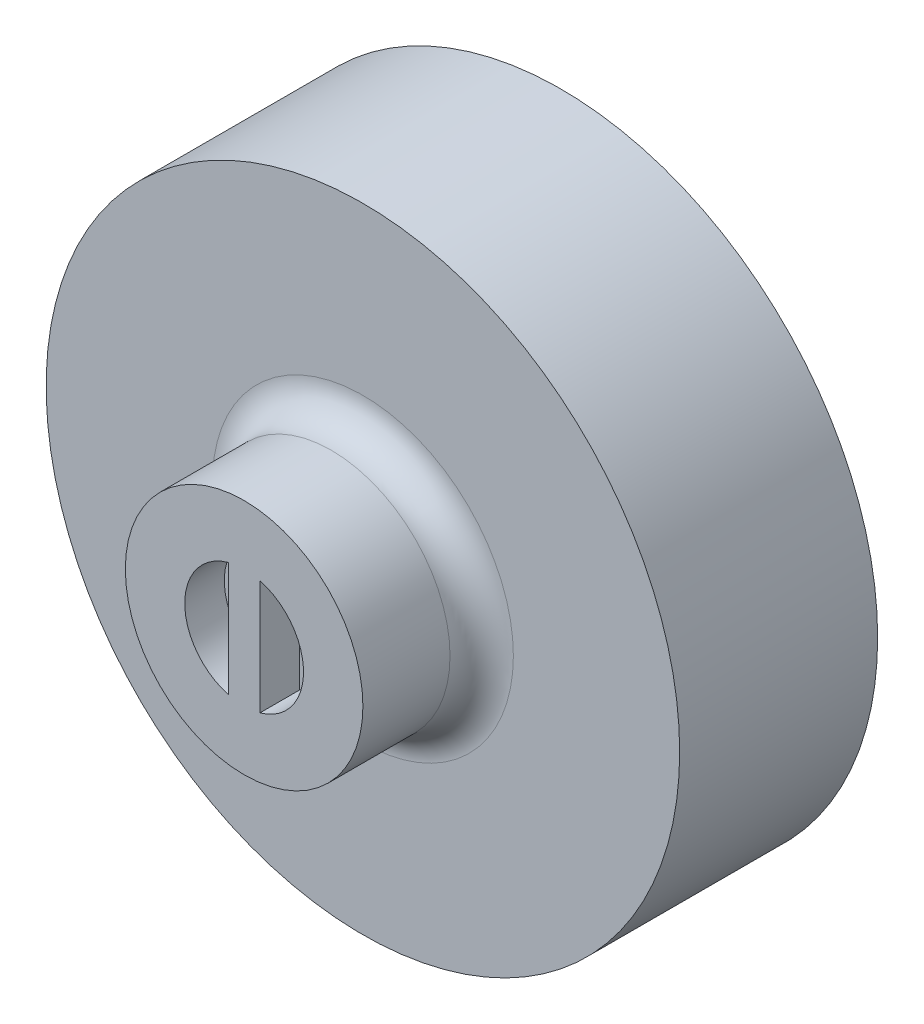
from build123d import *

# Parameters (mm, degrees)
SKETCH1_R           = 25.4
BOSS_EXTRUDE1_DEPTH = 15.875
SKETCH2_R           = 9.525
BOSS_EXTRUDE2_DEPTH = 9.525
FILLET2_R           = 2.54
CUT_EXTRUDE1_DEPTH  = 3.175


with BuildPart() as part:
    # Sketch1 → Boss-Extrude1 (new body)
    with BuildSketch(Plane.XY):
        Circle(SKETCH1_R)
    extrude(amount=-BOSS_EXTRUDE1_DEPTH)

    # Sketch2 → Boss-Extrude2 (add)
    with BuildSketch(Plane.XY):
        Circle(SKETCH2_R)
    extrude(amount=BOSS_EXTRUDE2_DEPTH)

    # Fillet2
    fillet2_edges = [part.edges().sort_by_distance(p)[0] for p in [
        (-9.525, 0, 0),
    ]]
    fillet(fillet2_edges, radius=FILLET2_R)

    # Sketch3 → Cut-Extrude1 (cut)
    with BuildSketch(Plane.XY.offset(9.525)):
        with BuildLine():
            Line((-1.27, 4.590044254), (-1.27, -4.590044254))
            ThreePointArc((-1.27, -4.590044254), (-4.7625, 0), (-1.27, 4.590044254))
        make_face()
        with BuildLine():
            Line((1.27, 4.590044254), (1.27, -4.590044254))
            ThreePointArc((1.27, -4.590044254), (4.7625, 0), (1.27, 4.590044254))
        make_face()
    extrude(amount=-CUT_EXTRUDE1_DEPTH, mode=Mode.SUBTRACT)


solid = part.part
